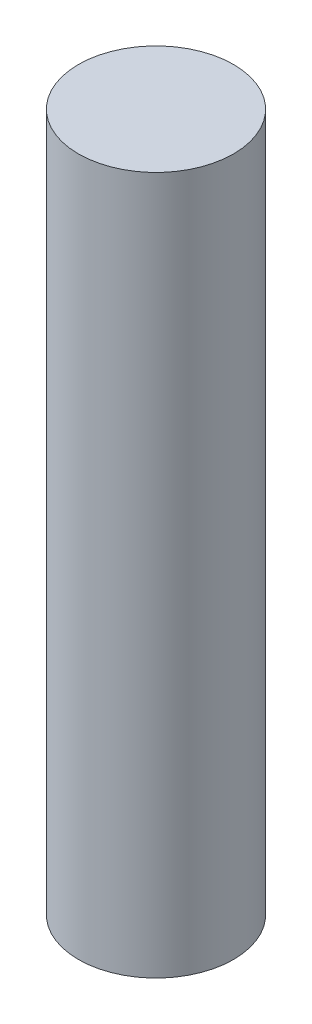
from build123d import *

# Parameters (mm, degrees)
SKETCH1_R           = 12.7
BOSS_EXTRUDE1_DEPTH = 114.3


with BuildPart() as part:
    # Sketch1 → Boss-Extrude1 (new body)
    with BuildSketch(Plane(origin=(0, 0, 0), x_dir=(1, 0, 0), z_dir=(0, 1, 0))):
        Circle(SKETCH1_R)
    extrude(amount=BOSS_EXTRUDE1_DEPTH)


solid = part.part
